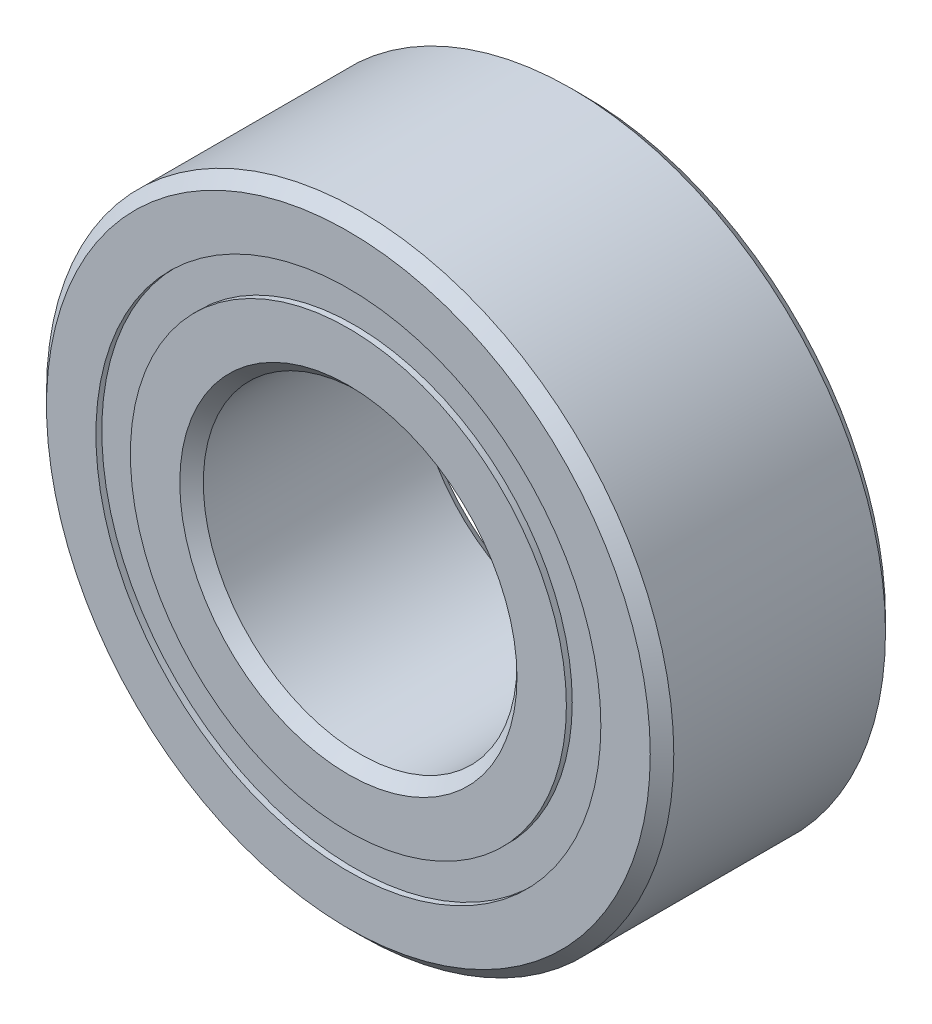
from build123d import *

# Parameters (mm, degrees)
CIRPATTERN1_COUNT = 12
SKETCH5_W         = 1.147826059
SKETCH5_H         = 0.697802198


with BuildPart() as part:
    # Sketch1 → Revolve1 (revolve)
    with BuildSketch(Plane(origin=(0, 0, 0), x_dir=(0, 0, -1), z_dir=(1, 0, 0))):
        with BuildLine():
            Line((2.143125, 6.35), (-2.143125, 6.35))
            Line((-2.143125, 6.35), (-2.38125, 6.111875))
            Line((-2.38125, 6.111875), (-2.38125, 5.111401099))
            Line((-2.38125, 5.111401099), (-1.058333333, 5.111401099))
            ThreePointArc((-1.058333333, 5.111401099), (0, 5.876861441), (1.058333333, 5.111401099))
            Line((1.058333333, 5.111401099), (2.38125, 5.111401099))
            Line((2.38125, 5.111401099), (2.38125, 6.111875))
            Line((2.38125, 6.111875), (2.143125, 6.35))
        make_face()
    revolve(axis=Axis((0, 0, 2.38125), (0, 0, -1)))


with BuildPart() as body_2:
    # Sketch3 → Revolve3 (revolve)
    with BuildSketch(Plane(origin=(0, 0, 0), x_dir=(0, 0, -1), z_dir=(1, 0, 0))):
        with BuildLine():
            Line((-1.058333333, 4.413598901), (-2.38125, 4.413598901))
            Line((-2.38125, 4.413598901), (-2.38125, 3.413125))
            Line((-2.38125, 3.413125), (-2.143125, 3.175))
            Line((-2.143125, 3.175), (2.143125, 3.175))
            Line((2.143125, 3.175), (2.38125, 3.413125))
            Line((2.38125, 3.413125), (2.38125, 4.413598901))
            Line((2.38125, 4.413598901), (1.058333333, 4.413598901))
            ThreePointArc((1.058333333, 4.413598901), (0, 3.648138559), (-1.058333333, 4.413598901))
        make_face()
    revolve(axis=Axis((0, 0, 2.38125), (0, 0, -1)))


with BuildPart() as body_3:
    # Sketch4 → Revolve4 (revolve)
    with BuildSketch(Plane(origin=(0, 0, 0), x_dir=(0, 0, -1), z_dir=(1, 0, 0))):
        with BuildLine():
            Line((-1.114361441, 4.7625), (1.114361441, 4.7625))
            ThreePointArc((1.114361441, 4.7625), (0, 5.876861441), (-1.114361441, 4.7625))
        make_face()
    revolve(axis=Axis((0, 4.7625, 1.114361441), (0, 0, -1)))


with BuildPart() as cirpattern1_1:
    # CirPattern1: pattern copy
    add(body_3.part.rotate(Axis((0, 0, 0), (0, 0, 1)), 1 * 360 / CIRPATTERN1_COUNT))


with BuildPart() as cirpattern1_2:
    # CirPattern1: pattern copy
    add(body_3.part.rotate(Axis((0, 0, 0), (0, 0, 1)), 2 * 360 / CIRPATTERN1_COUNT))


with BuildPart() as cirpattern1_3:
    # CirPattern1: pattern copy
    add(body_3.part.rotate(Axis((0, 0, 0), (0, 0, 1)), 3 * 360 / CIRPATTERN1_COUNT))


with BuildPart() as cirpattern1_4:
    # CirPattern1: pattern copy
    add(body_3.part.rotate(Axis((0, 0, 0), (0, 0, 1)), 4 * 360 / CIRPATTERN1_COUNT))


with BuildPart() as cirpattern1_5:
    # CirPattern1: pattern copy
    add(body_3.part.rotate(Axis((0, 0, 0), (0, 0, 1)), 5 * 360 / CIRPATTERN1_COUNT))


with BuildPart() as cirpattern1_6:
    # CirPattern1: pattern copy
    add(body_3.part.rotate(Axis((0, 0, 0), (0, 0, 1)), 6 * 360 / CIRPATTERN1_COUNT))


with BuildPart() as cirpattern1_7:
    # CirPattern1: pattern copy
    add(body_3.part.rotate(Axis((0, 0, 0), (0, 0, 1)), 7 * 360 / CIRPATTERN1_COUNT))


with BuildPart() as cirpattern1_8:
    # CirPattern1: pattern copy
    add(body_3.part.rotate(Axis((0, 0, 0), (0, 0, 1)), 8 * 360 / CIRPATTERN1_COUNT))


with BuildPart() as cirpattern1_9:
    # CirPattern1: pattern copy
    add(body_3.part.rotate(Axis((0, 0, 0), (0, 0, 1)), 9 * 360 / CIRPATTERN1_COUNT))


with BuildPart() as cirpattern1_10:
    # CirPattern1: pattern copy
    add(body_3.part.rotate(Axis((0, 0, 0), (0, 0, 1)), 10 * 360 / CIRPATTERN1_COUNT))


with BuildPart() as cirpattern1_11:
    # CirPattern1: pattern copy
    add(body_3.part.rotate(Axis((0, 0, 0), (0, 0, 1)), 11 * 360 / CIRPATTERN1_COUNT))


with BuildPart() as body_15:
    # Sketch5 → Revolve5 (revolve)
    with BuildSketch(Plane(origin=(0, 0, 0), x_dir=(0, 0, -1), z_dir=(1, 0, 0))):
        with Locations((-1.688274471, 4.7625)):
            Rectangle(SKETCH5_W, SKETCH5_H)
        with Locations((1.688274471, 4.7625)):
            Rectangle(SKETCH5_W, SKETCH5_H)
    revolve(axis=Axis((0, 0, 2.38125), (0, 0, -1)))


solid = Compound([part.part, body_2.part, body_3.part, cirpattern1_1.part, cirpattern1_2.part, cirpattern1_3.part, cirpattern1_4.part, cirpattern1_5.part, cirpattern1_6.part, cirpattern1_7.part, cirpattern1_8.part, cirpattern1_9.part, cirpattern1_10.part, cirpattern1_11.part, body_15.part])
